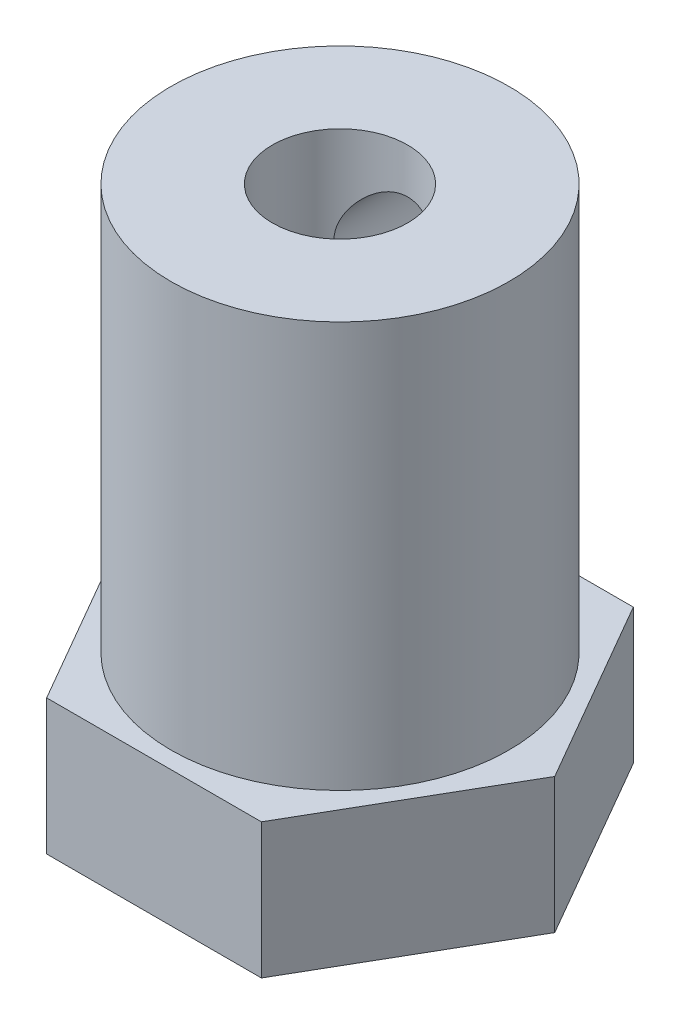
from build123d import *

# Parameters (mm, degrees)
BOSS_EXTRUDE1_DEPTH     = 4
SKETCH2_R               = 5
BOSS_EXTRUDE2_DEPTH     = 12
SKETCH3_R               = 2
CUT_EXTRUDE1_DEPTH      = 1
CUT_EXTRUDE1_DEPTH_BACK = 17
SKETCH4_R               = 1.5
CUT_EXTRUDE2_DEPTH      = 12


with BuildPart() as part:
    # Sketch1 → Boss-Extrude1 (new body)
    with BuildSketch(Plane(origin=(0, 0, 0), x_dir=(1, 0, 0), z_dir=(0, 1, 0))):
        Polygon((6.350852961, 0), (3.175426481, 5.5), (-3.175426481, 5.5), (-6.350852961, 0), (-3.175426481, -5.5), (3.175426481, -5.5), align=None)
    extrude(amount=BOSS_EXTRUDE1_DEPTH)

    # Sketch2 → Boss-Extrude2 (add)
    with BuildSketch(Plane(origin=(0, 4, 0), x_dir=(1, 0, 0), z_dir=(0, 1, 0))):
        Circle(SKETCH2_R)
    extrude(amount=BOSS_EXTRUDE2_DEPTH)

    # Sketch3 → Cut-Extrude1 (cut, two sides)
    with BuildSketch(Plane(origin=(0, 16, 0), x_dir=(1, 0, 0), z_dir=(0, 1, 0))) as cut_extrude1_sk:
        Circle(SKETCH3_R)
    extrude(amount=CUT_EXTRUDE1_DEPTH, mode=Mode.SUBTRACT)
    extrude(cut_extrude1_sk.sketch, amount=-CUT_EXTRUDE1_DEPTH_BACK, mode=Mode.SUBTRACT)

    # Sketch4 → Cut-Extrude2 (cut)
    with BuildSketch(Plane.XY):
        with Locations((0, 13.169812353)):
            Circle(SKETCH4_R)
    extrude(amount=-CUT_EXTRUDE2_DEPTH, mode=Mode.SUBTRACT)


solid = part.part
